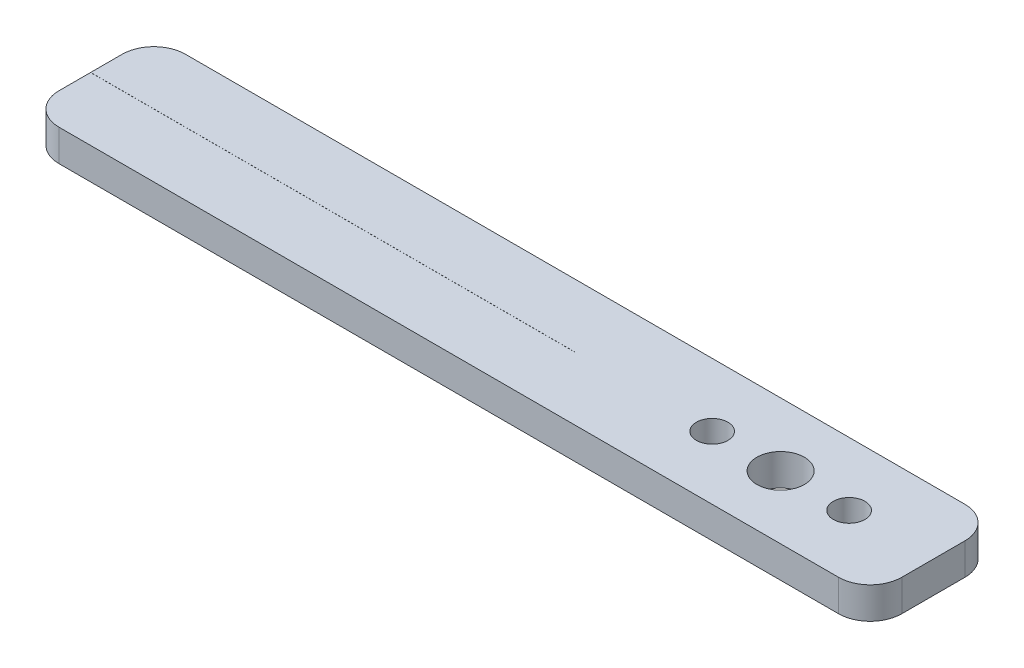
from build123d import *

# Parameters (mm, degrees)
BOSS_EXTRUDE1_DEPTH = 3
SKETCH2_R           = 1.5
SKETCH2_R_2         = 2.25
SKETCH2_W           = 45.952575141
SKETCH2_H           = 0.01
CUT_EXTRUDE1_DEPTH  = 4


with BuildPart() as part:
    # Sketch1 → Boss-Extrude1 (new body)
    with BuildSketch(Plane(origin=(0, 0, 0), x_dir=(1, 0, 0), z_dir=(0, 1, 0))):
        with BuildLine():
            Line((-37, 4), (37, 4))
            ThreePointArc((37, 4), (39.121320344, 3.121320344), (40, 1))
            Line((40, 1), (40, -5))
            ThreePointArc((40, -5), (39.121320344, -7.121320344), (37, -8))
            Line((37, -8), (-37, -8))
            ThreePointArc((-37, -8), (-39.121320344, -7.121320344), (-40, -5))
            Line((-40, -5), (-40, 1))
            ThreePointArc((-40, 1), (-39.121320344, 3.121320344), (-37, 4))
        make_face()
    extrude(amount=BOSS_EXTRUDE1_DEPTH)

    # Sketch2 → Cut-Extrude1 (cut, through all)
    with BuildSketch(Plane(origin=(0, 3, 0), x_dir=(1, 0, 0), z_dir=(0, 1, 0))):
        with Locations((32, -2)):
            Circle(SKETCH2_R)
        with Locations((25.5, -2)):
            Circle(SKETCH2_R_2)
        with Locations((19, -2)):
            Circle(SKETCH2_R)
        with Locations((-17.02371243, -2)):
            Rectangle(SKETCH2_W, SKETCH2_H)
    extrude(amount=-CUT_EXTRUDE1_DEPTH, mode=Mode.SUBTRACT)


solid = part.part
